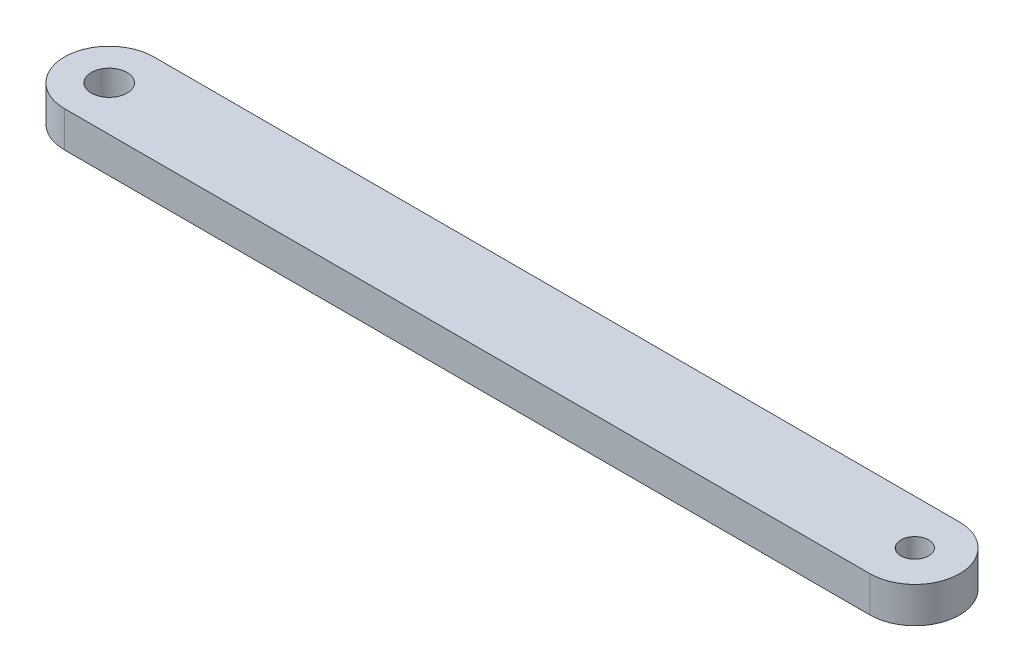
from build123d import *

# Parameters (mm, degrees)
SKETCH1_R           = 2
SKETCH1_R_2         = 1.55
BOSS_EXTRUDE1_DEPTH = 4


with BuildPart() as part:
    # Sketch1 → Boss-Extrude1 (new body)
    with BuildSketch(Plane(origin=(0, 0, 0), x_dir=(1, 0, 0), z_dir=(0, 1, 0))):
        with BuildLine():
            Line((0, -5), (-90, -5))
            ThreePointArc((-90, -5), (-95, 0), (-90, 5))
            Line((-90, 5), (0, 5))
            ThreePointArc((0, 5), (5, 0), (0, -5))
        make_face()
        with Locations((-90, 0)):
            Circle(SKETCH1_R, mode=Mode.SUBTRACT)
        Circle(SKETCH1_R_2, mode=Mode.SUBTRACT)
    extrude(amount=BOSS_EXTRUDE1_DEPTH)


solid = part.part
